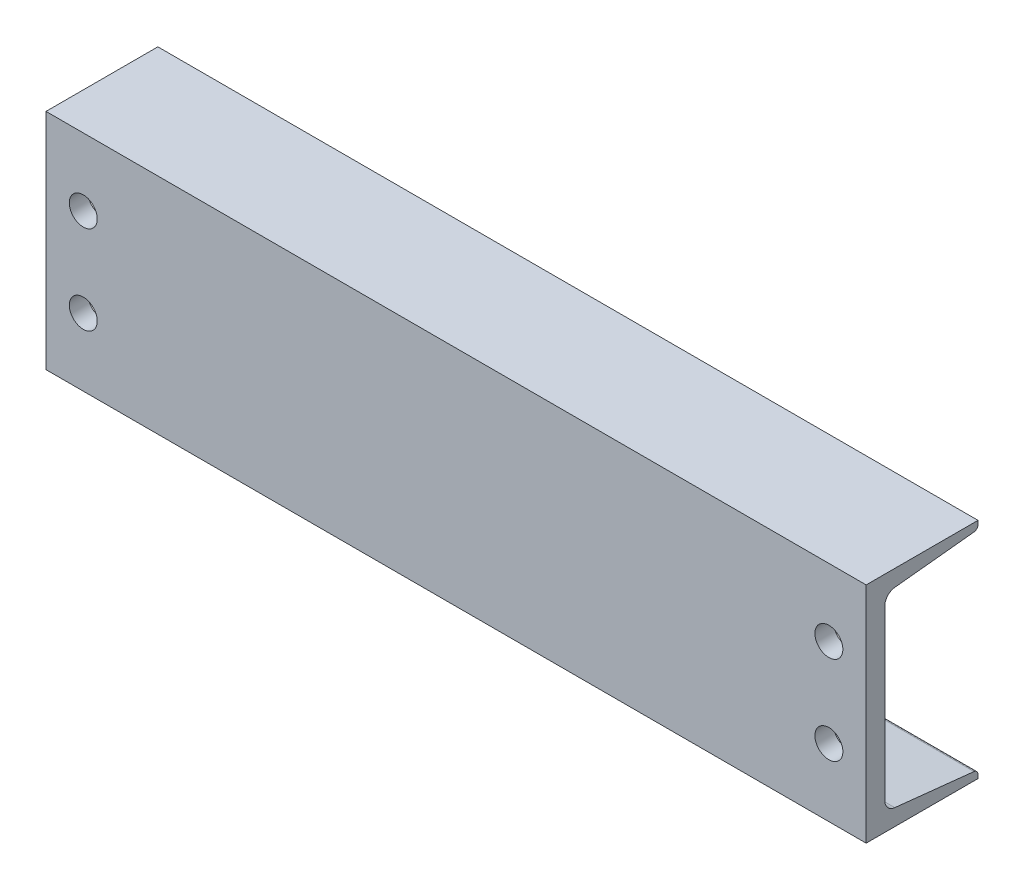
from build123d import *

# Parameters (mm, degrees)
BOSS_EXTRUDE1_DEPTH = 279.4
CUT_EXTRUDE1_REACH  = 78.2
SKETCH2_R           = 9.525
CUT_EXTRUDE2_REACH  = 154.4
SKETCH3_R           = 9.525


with BuildPart() as part:
    # Sketch1 → Boss-Extrude1 (new body, symmetric)
    with BuildSketch(Plane(origin=(0, 0, 0), x_dir=(0, 0, -1), z_dir=(1, 0, 0))):
        with BuildLine():
            Line((-48.8061, -76.2), (-48.8061, 76.2))
            Line((-48.8061, 76.2), (27.3939, 76.2))
            Line((27.3939, 76.2), (27.3939, 73.710744653))
            ThreePointArc((27.3939, 73.710744653), (26.61173954, 71.672050174), (24.666685315, 70.679672107))
            Line((24.666685315, 70.679672107), (-29.288063286, 64.969518115))
            ThreePointArc((-29.288063286, 64.969518115), (-34.150698849, 62.488572947), (-36.1061, 57.391836749))
            Line((-36.1061, 57.391836749), (-36.1061, -57.391836749))
            ThreePointArc((-36.1061, -57.391836749), (-34.150698849, -62.488572947), (-29.288063286, -64.969518115))
            Line((-29.288063286, -64.969518115), (24.666685315, -70.679672107))
            ThreePointArc((24.666685315, -70.679672107), (26.61173954, -71.672050174), (27.3939, -73.710744653))
            Line((27.3939, -73.710744653), (27.3939, -76.2))
            Line((27.3939, -76.2), (-48.8061, -76.2))
        make_face()
    extrude(amount=BOSS_EXTRUDE1_DEPTH, both=True)

    # Sketch2 → Cut-Extrude1 (cut, up to next)
    with BuildSketch(Plane.XY.offset(48.8061), mode=Mode.PRIVATE) as cut_extrude1_sk1:
        with Locations((-254, 30.1625)):
            Circle(SKETCH2_R)
    cut_extrude1_tool1 = extrude(cut_extrude1_sk1.sketch, amount=-CUT_EXTRUDE1_REACH, mode=Mode.PRIVATE) & part.part
    add(cut_extrude1_tool1.solids().sort_by_distance((-254, 30.1625, 48.8061))[0], mode=Mode.SUBTRACT)
    # Sketch2 → Cut-Extrude1 (cut, up to next)
    with BuildSketch(Plane.XY.offset(48.8061), mode=Mode.PRIVATE) as cut_extrude1_sk2:
        with Locations((-254, -30.1625)):
            Circle(SKETCH2_R)
    cut_extrude1_tool2 = extrude(cut_extrude1_sk2.sketch, amount=-CUT_EXTRUDE1_REACH, mode=Mode.PRIVATE) & part.part
    add(cut_extrude1_tool2.solids().sort_by_distance((-254, -30.1625, 48.8061))[0], mode=Mode.SUBTRACT)
    # Sketch2 → Cut-Extrude1 (cut, up to next)
    with BuildSketch(Plane.XY.offset(48.8061), mode=Mode.PRIVATE) as cut_extrude1_sk3:
        with Locations((254, -30.1625)):
            Circle(SKETCH2_R)
    cut_extrude1_tool3 = extrude(cut_extrude1_sk3.sketch, amount=-CUT_EXTRUDE1_REACH, mode=Mode.PRIVATE) & part.part
    add(cut_extrude1_tool3.solids().sort_by_distance((254, -30.1625, 48.8061))[0], mode=Mode.SUBTRACT)
    # Sketch2 → Cut-Extrude1 (cut, up to next)
    with BuildSketch(Plane.XY.offset(48.8061), mode=Mode.PRIVATE) as cut_extrude1_sk4:
        with Locations((254, 30.1625)):
            Circle(SKETCH2_R)
    cut_extrude1_tool4 = extrude(cut_extrude1_sk4.sketch, amount=-CUT_EXTRUDE1_REACH, mode=Mode.PRIVATE) & part.part
    add(cut_extrude1_tool4.solids().sort_by_distance((254, 30.1625, 48.8061))[0], mode=Mode.SUBTRACT)

    # Sketch3 → Cut-Extrude2 (cut, up to next)
    with BuildSketch(Plane.XZ.offset(76.2), mode=Mode.PRIVATE) as cut_extrude2_sk1:
        with Locations((-165.1, 10.7061)):
            Circle(SKETCH3_R)
    cut_extrude2_tool1 = extrude(cut_extrude2_sk1.sketch, amount=-CUT_EXTRUDE2_REACH, mode=Mode.PRIVATE) & part.part
    add(cut_extrude2_tool1.solids().sort_by_distance((-165.1, -76.2, 10.7061))[0], mode=Mode.SUBTRACT)
    # Sketch3 → Cut-Extrude2 (cut, up to next)
    with BuildSketch(Plane.XZ.offset(76.2), mode=Mode.PRIVATE) as cut_extrude2_sk2:
        with Locations((165.1, 10.7061)):
            Circle(SKETCH3_R)
    cut_extrude2_tool2 = extrude(cut_extrude2_sk2.sketch, amount=-CUT_EXTRUDE2_REACH, mode=Mode.PRIVATE) & part.part
    add(cut_extrude2_tool2.solids().sort_by_distance((165.1, -76.2, 10.7061))[0], mode=Mode.SUBTRACT)


solid = part.part
